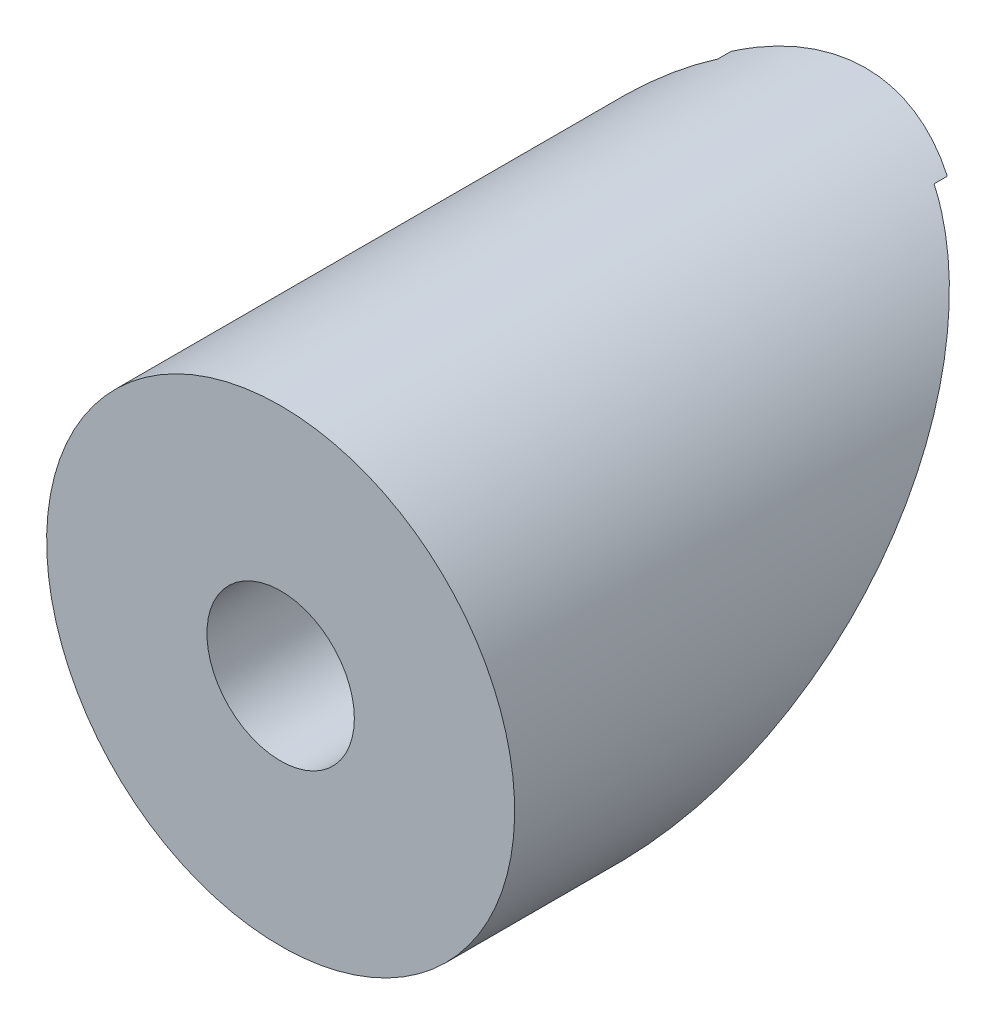
from build123d import *

# Parameters (mm, degrees)
BOSS_EXTRUDE1_DEPTH     = 9.525
SKETCH2_OUTSIDE_W       = 27.65
SKETCH2_OUTSIDE_H       = 27.65
SKETCH2_OUTSIDE_R       = 6.35
CUT_EXTRUDE1_DEPTH      = 20.05
CUT_EXTRUDE1_DEPTH_BACK = 1
SKETCH3_R               = 2
CUT_EXTRUDE2_DEPTH      = 16.875
CUT_EXTRUDE6_DEPTH      = 7.35
CUT_EXTRUDE6_DEPTH_BACK = 7.35


with BuildPart() as part:
    # Sketch1 → Boss-Extrude1 (new body, symmetric)
    with BuildSketch(Plane(origin=(0, 0, 0), x_dir=(0, 0, -1), z_dir=(1, 0, 0))):
        Polygon((19.05, 9.525), (0, -9.525), (0, 9.525), align=None)
    extrude(amount=BOSS_EXTRUDE1_DEPTH, both=True)

    # Sketch2 outside → Cut-Extrude1 (cut, two sides)
    with BuildSketch(Plane(origin=(0, -2.789807909, 0), x_dir=(1, 0, 0), z_dir=(0, 0, -1))) as cut_extrude1_sk:
        with Locations((0, -2.79)):
            Rectangle(SKETCH2_OUTSIDE_W, SKETCH2_OUTSIDE_H)
        with Locations((0, -2.789807909)):
            Circle(SKETCH2_OUTSIDE_R, mode=Mode.SUBTRACT)
    extrude(amount=CUT_EXTRUDE1_DEPTH, mode=Mode.SUBTRACT)
    extrude(cut_extrude1_sk.sketch, amount=-CUT_EXTRUDE1_DEPTH_BACK, mode=Mode.SUBTRACT)

    # Sketch3 → Cut-Extrude2 (cut, through all)
    with BuildSketch(Plane.XY):
        Circle(SKETCH3_R)
    extrude(amount=-CUT_EXTRUDE2_DEPTH, mode=Mode.SUBTRACT)

    # Sketch11 → Cut-Extrude6 (cut, two sides)
    with BuildSketch(Plane(origin=(0, 0, 0), x_dir=(0, 0, -1), z_dir=(1, 0, 0))) as cut_extrude6_sk:
        Polygon((15.15657951, 5.63157951), (14.797369265, 5.63157951), (3.89342049, -5.272369265), (3.89342049, -5.63157951), align=None)
    extrude(amount=CUT_EXTRUDE6_DEPTH, mode=Mode.SUBTRACT)
    extrude(cut_extrude6_sk.sketch, amount=-CUT_EXTRUDE6_DEPTH_BACK, mode=Mode.SUBTRACT)


solid = part.part
